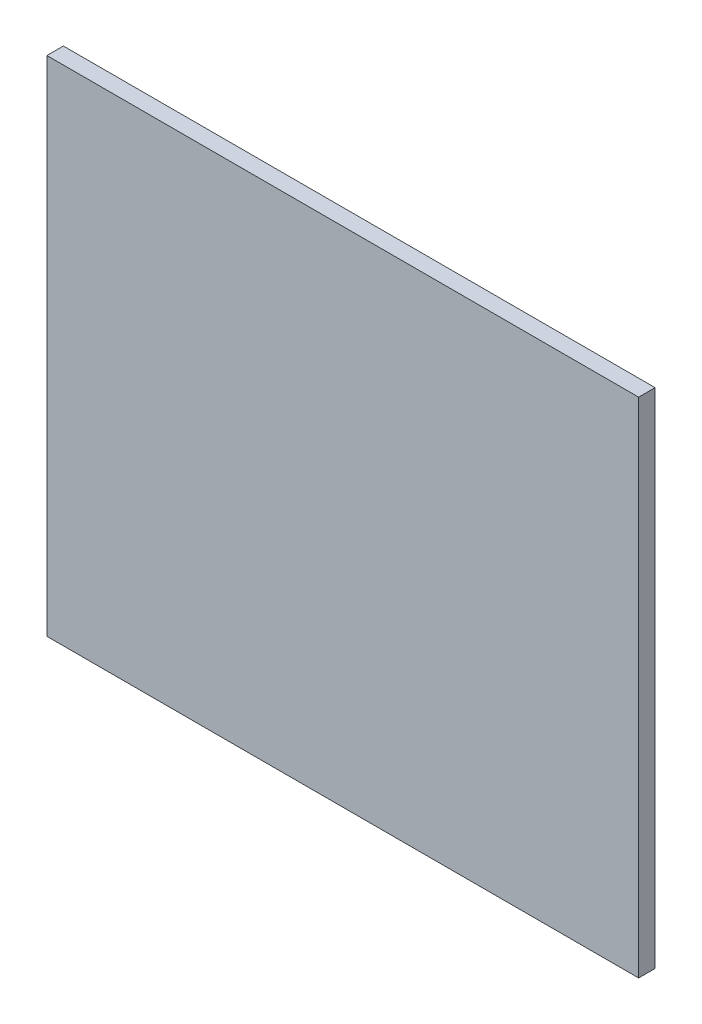
from build123d import *

# Parameters (mm, degrees)
SKETCH1_W           = 647
SKETCH1_H           = 550
BOSS_EXTRUDE1_DEPTH = 18


with BuildPart() as part:
    # Sketch1 → Boss-Extrude1 (new body)
    with BuildSketch(Plane.XY):
        Rectangle(SKETCH1_W, SKETCH1_H)
    extrude(amount=BOSS_EXTRUDE1_DEPTH)


solid = part.part
